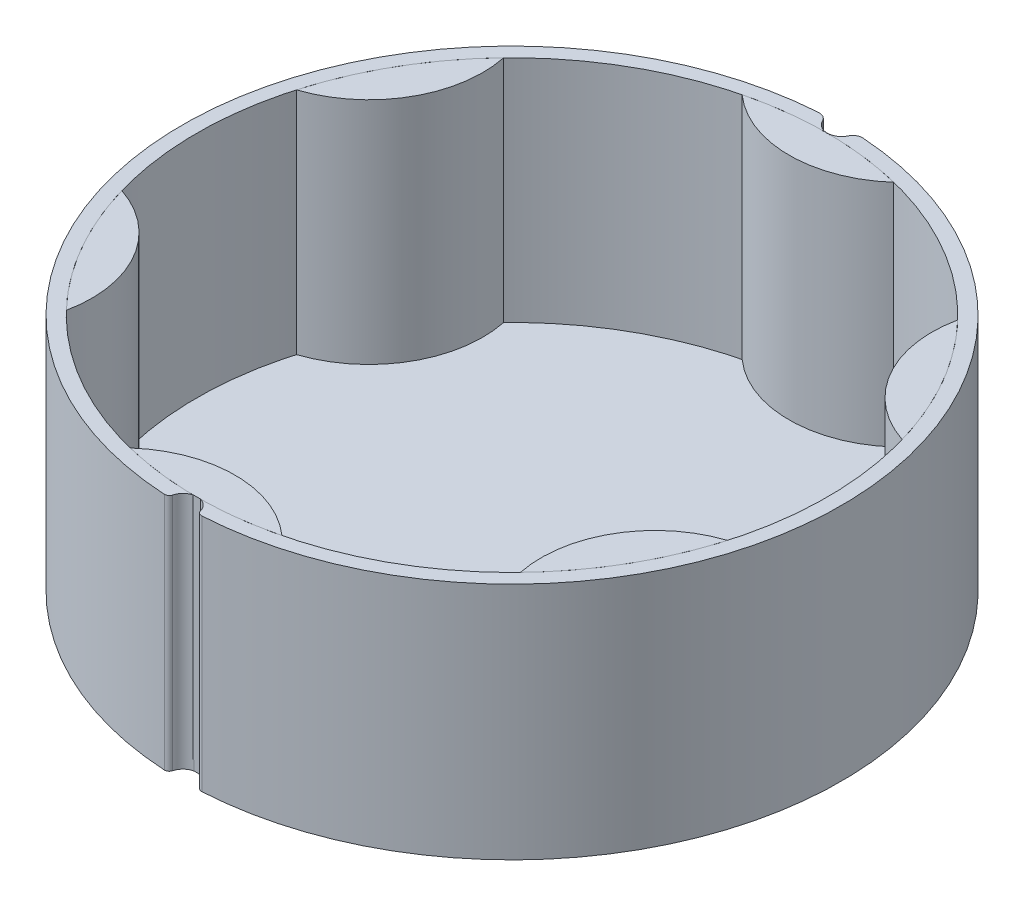
from build123d import *

# Parameters (mm, degrees)
BOSS_EXTRUDE1_DEPTH = 25
CUT_EXTRUDE2_REACH  = 28
CUT_EXTRUDE2_START  = 1
BOSS_EXTRUDE2_DEPTH = 25
CIRPATTERN2_COUNT   = 6


with BuildPart() as part:
    # Sketch1 → Boss-Extrude1 (new body)
    with BuildSketch(Plane(origin=(0, 0, 0), x_dir=(1, 0, 0), z_dir=(0, 1, 0))):
        with BuildLine():
            ThreePointArc((1.451818925, -34.068556857), (1.641248992, -34.346908706), (1.964225605, -34.442038138))
            ThreePointArc((1.964225605, -34.442038138), (34.499528846, -0.178302888), (2.324135821, 34.423627607))
            ThreePointArc((2.324135821, 34.423627607), (1.751838249, 34.289058819), (1.354061739, 33.856153382))
            ThreePointArc((1.354061739, 33.856153382), (0, 33.001534515), (-1.354061739, 33.856153382))
            ThreePointArc((-1.354061739, 33.856153382), (-1.751838249, 34.289058819), (-2.324135821, 34.423627607))
            ThreePointArc((-2.324135821, 34.423627607), (-34.499528846, -0.178302888), (-1.964225605, -34.442038138))
            ThreePointArc((-1.964225605, -34.442038138), (-1.641248992, -34.346908706), (-1.451818925, -34.068556857))
            ThreePointArc((-1.451818925, -34.068556857), (0, -32.945679925), (1.451818925, -34.068556857))
        make_face()
    extrude(amount=BOSS_EXTRUDE1_DEPTH)

    # Sketch2 → Cut-Extrude2 (cut, up to next)
    with BuildSketch(Plane(origin=(0, 0, 0), x_dir=(1, 0, 0), z_dir=(0, 1, 0)).offset(CUT_EXTRUDE2_START), mode=Mode.PRIVATE) as cut_extrude2_sk1:
        with BuildLine():
            ThreePointArc((-7.94101302, 32.03030303), (-20.334042519, -25.990896769), (33, 0))
            ThreePointArc((33, 0), (25.990896769, 20.334042519), (7.94101302, 32.03030303))
            ThreePointArc((7.94101302, 32.03030303), (0, 29), (-7.94101302, 32.03030303))
        make_face()
    cut_extrude2_tool1 = extrude(cut_extrude2_sk1.sketch, amount=CUT_EXTRUDE2_REACH, mode=Mode.PRIVATE) & part.part
    add(cut_extrude2_tool1.solids().sort_by_distance((0, 1, 0.399773))[0], mode=Mode.SUBTRACT)
    # Sketch2 → Cut-Extrude2 (cut, up to next)
    with BuildSketch(Plane(origin=(0, 0, 0), x_dir=(1, 0, 0), z_dir=(0, 1, 0)).offset(CUT_EXTRUDE2_START), mode=Mode.PRIVATE) as cut_extrude2_sk2:
        with BuildLine():
            ThreePointArc((-7.94101302, 32.03030303), (0, 29), (7.94101302, 32.03030303))
            ThreePointArc((7.94101302, 32.03030303), (0, 33), (-7.94101302, 32.03030303))
        make_face()
    cut_extrude2_tool2 = extrude(cut_extrude2_sk2.sketch, amount=CUT_EXTRUDE2_REACH, mode=Mode.PRIVATE) & part.part
    add(cut_extrude2_tool2.solids().sort_by_distance((0, 1, -31.18796))[0], mode=Mode.SUBTRACT)


with BuildPart() as body_2:
    # Sketch2_2 → Boss-Extrude2 (new body)
    with BuildSketch(Plane(origin=(0, 0, 0), x_dir=(1, 0, 0), z_dir=(0, 1, 0))):
        with BuildLine():
            ThreePointArc((-7.94101302, 32.03030303), (0, 29), (7.94101302, 32.03030303))
            ThreePointArc((7.94101302, 32.03030303), (0, 33), (-7.94101302, 32.03030303))
        make_face()
    extrude(amount=BOSS_EXTRUDE2_DEPTH)


with BuildPart() as cirpattern2_1:
    # CirPattern2: pattern copy
    add(body_2.part.rotate(Axis((0, 0, 0), (0, 1, 0)), 1 * 360 / CIRPATTERN2_COUNT))


with BuildPart() as cirpattern2_2:
    # CirPattern2: pattern copy
    add(body_2.part.rotate(Axis((0, 0, 0), (0, 1, 0)), 2 * 360 / CIRPATTERN2_COUNT))


with BuildPart() as cirpattern2_3:
    # CirPattern2: pattern copy
    add(body_2.part.rotate(Axis((0, 0, 0), (0, 1, 0)), 3 * 360 / CIRPATTERN2_COUNT))


with BuildPart() as cirpattern2_4:
    # CirPattern2: pattern copy
    add(body_2.part.rotate(Axis((0, 0, 0), (0, 1, 0)), 4 * 360 / CIRPATTERN2_COUNT))


with BuildPart() as cirpattern2_5:
    # CirPattern2: pattern copy
    add(body_2.part.rotate(Axis((0, 0, 0), (0, 1, 0)), 5 * 360 / CIRPATTERN2_COUNT))


solid = Compound([part.part, body_2.part, cirpattern2_1.part, cirpattern2_2.part, cirpattern2_3.part, cirpattern2_4.part, cirpattern2_5.part])
